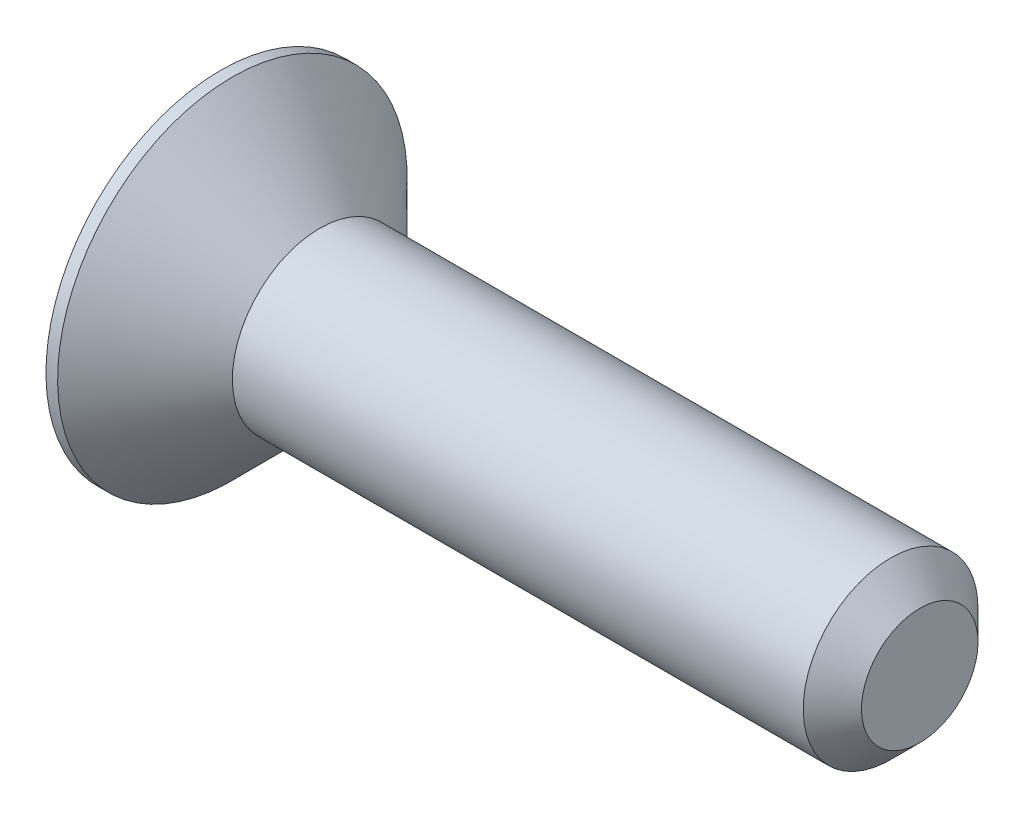
from build123d import *

# Parameters (mm, degrees)
CHANFREIN1_SIZE         = 0.5
ENL_V_MAT_EXTRU_1_DEPTH = 1.2


with BuildPart() as part:
    # Esquisse1 → Révolution1 (revolve)
    with BuildSketch(Plane.XY):
        Polygon((0, 0), (0, 3), (0.2, 3), (1.7, 1.5), (12, 1.5), (12, 0), align=None)
    revolve(axis=Axis((12, 0, 0), (-1, 0, 0)))

    # Chanfrein1
    chanfrein1_edges = [part.edges().sort_by_distance(p)[0] for p in [
        (12, -1.5, 0),
    ]]
    chamfer(chanfrein1_edges, length=CHANFREIN1_SIZE)

    # Esquisse2 → Enlèv. mat.-Extru.1 (cut)
    with BuildSketch(Plane.ZY):
        Polygon((0, 1.154700538), (-1, 0.577350269), (-1, -0.577350269), (0, -1.154700538), (1, -0.577350269), (1, 0.577350269), align=None)
    extrude(amount=-ENL_V_MAT_EXTRU_1_DEPTH, mode=Mode.SUBTRACT)


solid = part.part
